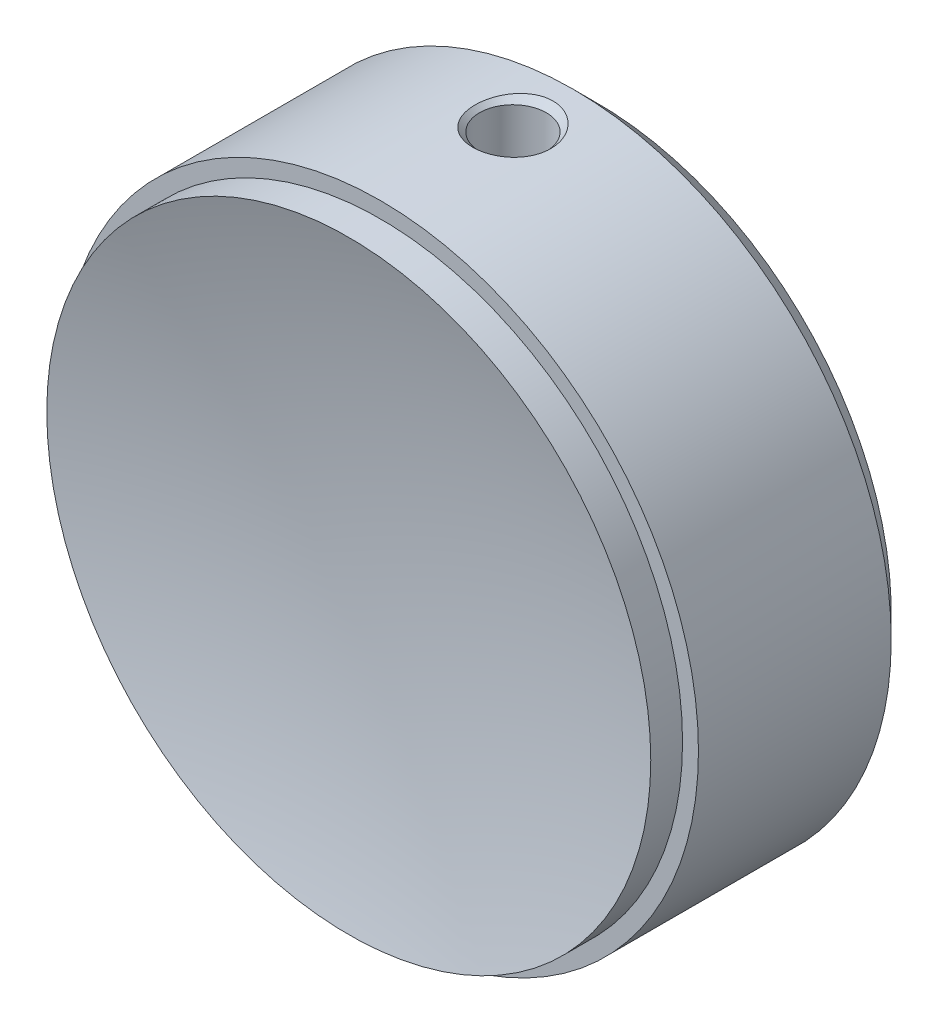
from build123d import *

# Parameters (mm, degrees)
M3_TAPPED_HOLE1_D           = 2.5
M3_TAPPED_HOLE1_DEPTH       = 7.5
M3_TAPPED_HOLE1_TIP         = 0.751075774
M5_TAPPED_HOLE1_D           = 4.2
M5_TAPPED_HOLE1_DEPTH       = 12.4
M5_TAPPED_HOLE1_CSINK_D     = 5.05
M5_TAPPED_HOLE1_CSINK_ANGLE = 90
M5_TAPPED_HOLE1_TIP         = 1.2618073


with BuildPart() as part:
    # Sketch1 → Revolve1 (revolve)
    with BuildSketch(Plane(origin=(0, 0, 0), x_dir=(1, 0, 0), z_dir=(0, 1, 0))):
        with BuildLine():
            ThreePointArc((0, -6.5), (-4.596194078, -4.596194078), (-6.5, 0))
            Line((-6.5, 0), (-18.5, 0))
            Line((-18.5, 0), (-20, -1.5))
            Line((-20, -1.5), (-20, -13.627898949))
            Line((-20, -13.627898949), (-19, -13.627898949))
            Line((-19, -13.627898949), (-19, -15.627898949))
            ThreePointArc((-19, -15.627898949), (-9.590436029, -13.660086986), (0, -13))
            Line((0, -13), (0, -6.5))
        make_face()
    revolve(axis=Axis((0, 0, -56.528501867), (0, 0, 1)))

    # M3 Tapped Hole1
    with Locations(Plane(origin=(0, 0, 0), x_dir=(-1, 0, 0), z_dir=(0, 0, -1))):
        with Locations((0, -10.795), (-9.348744234, 5.3975), (9.348744234, 5.3975)):
            Hole(M3_TAPPED_HOLE1_D / 2, depth=M3_TAPPED_HOLE1_DEPTH)
            with Locations((0, 0, -(M3_TAPPED_HOLE1_DEPTH + M3_TAPPED_HOLE1_TIP / 2))):  # 118° drill point
                Cone(0, M3_TAPPED_HOLE1_D / 2, M3_TAPPED_HOLE1_TIP, mode=Mode.SUBTRACT)

    # M5 Tapped Hole1
    with Locations(Plane(origin=(0, 20, 0), x_dir=(1, 0, 0), z_dir=(0, 1, 0))):
        with Locations((0, -5.3)):
            CounterSinkHole(M5_TAPPED_HOLE1_D / 2, M5_TAPPED_HOLE1_CSINK_D / 2, depth=M5_TAPPED_HOLE1_DEPTH, counter_sink_angle=M5_TAPPED_HOLE1_CSINK_ANGLE)
            with Locations((0, 0, -(M5_TAPPED_HOLE1_DEPTH + M5_TAPPED_HOLE1_TIP / 2))):  # 118° drill point
                Cone(0, M5_TAPPED_HOLE1_D / 2, M5_TAPPED_HOLE1_TIP, mode=Mode.SUBTRACT)


solid = part.part
